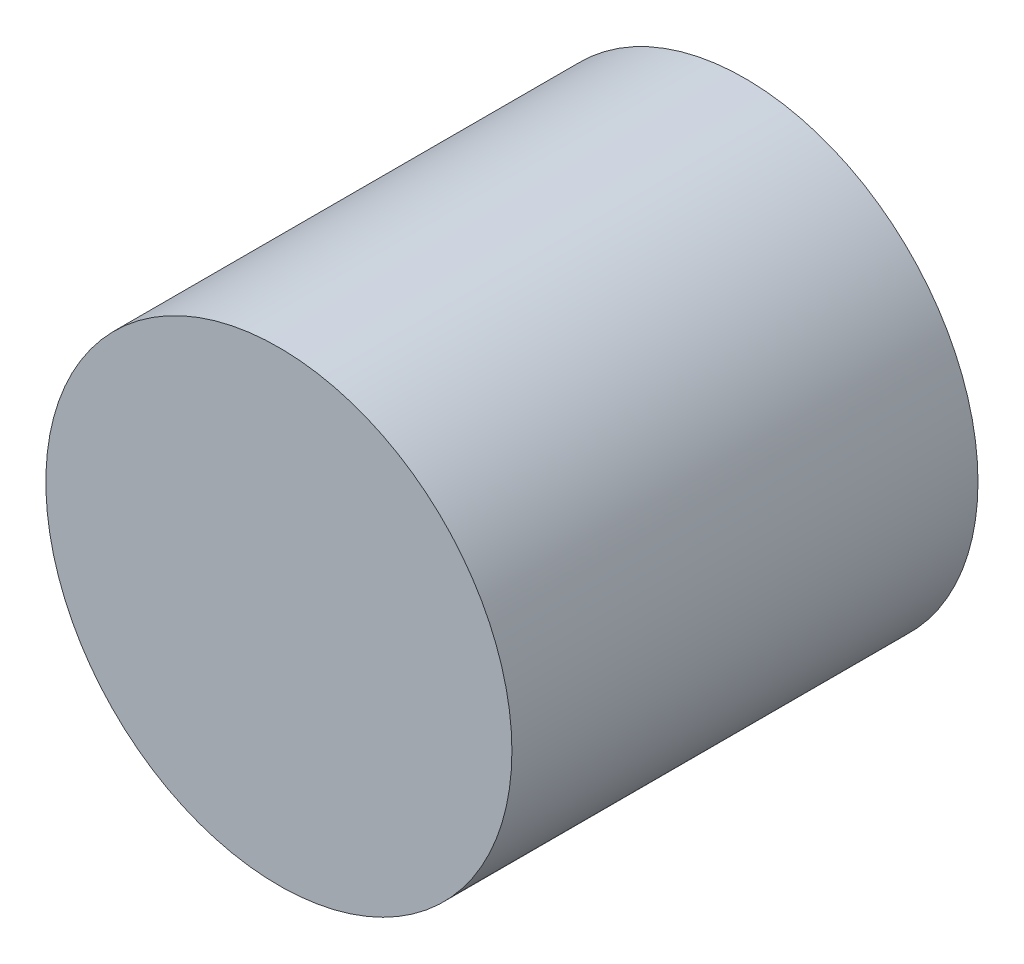
from build123d import *

# Parameters (mm, degrees)
SKIZZE1_R                       = 7.5
AUFSATZ_LINEAR_AUSTRAGEN1_DEPTH = 7.5


with BuildPart() as part:
    # Skizze1 → Aufsatz-Linear austragen1 (new body, symmetric)
    with BuildSketch(Plane.XY):
        Circle(SKIZZE1_R)
    extrude(amount=AUFSATZ_LINEAR_AUSTRAGEN1_DEPTH, both=True)


solid = part.part
